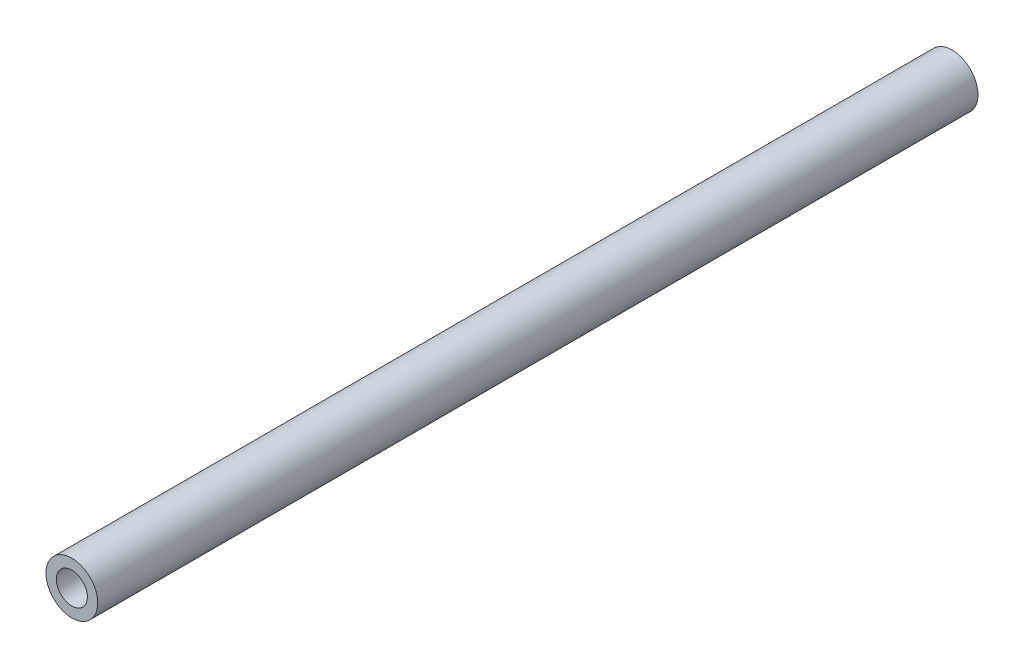
from build123d import *

# Parameters (mm, degrees)
SKETCH1_R           = 5
SKETCH1_R_2         = 3
BOSS_EXTRUDE1_DEPTH = 170


with BuildPart() as part:
    # Sketch1 → Boss-Extrude1 (new body)
    with BuildSketch(Plane.XY):
        Circle(SKETCH1_R)
        Circle(SKETCH1_R_2, mode=Mode.SUBTRACT)
    extrude(amount=BOSS_EXTRUDE1_DEPTH)


solid = part.part
